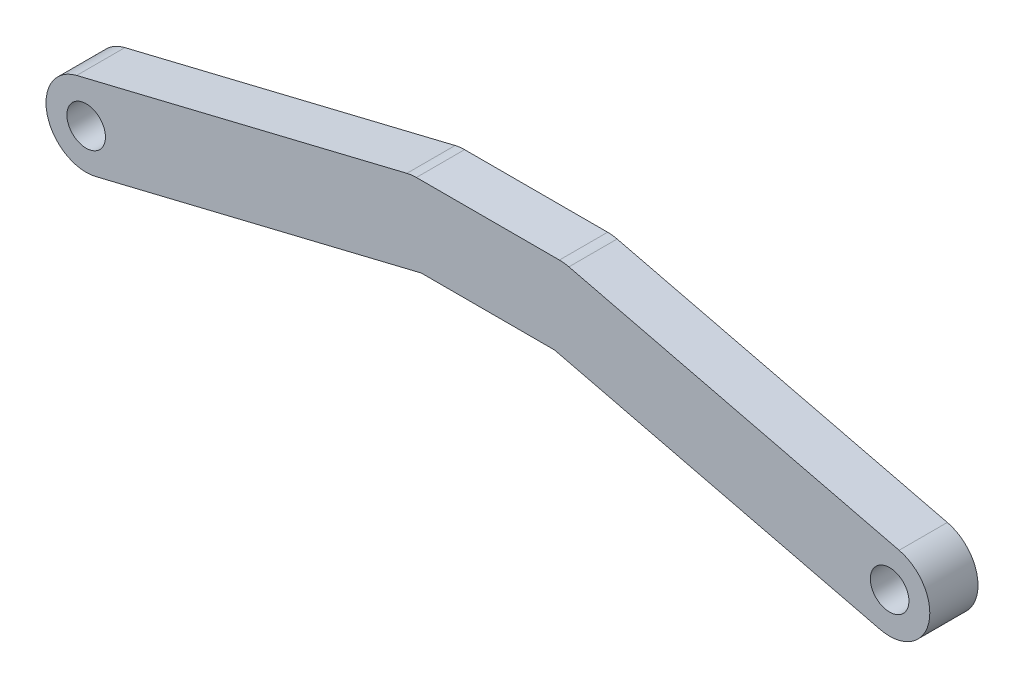
from build123d import *

# Parameters (mm, degrees)
SKETCH1_R           = 1.2
BOSS_EXTRUDE1_DEPTH = 1.5


with BuildPart() as part:
    # Sketch1 → Boss-Extrude1 (new body, symmetric)
    with BuildSketch(Plane.XY):
        with BuildLine():
            Line((-24.40896688, -2.429131501), (-4.150358361, 2.5))
            Line((-4.150358361, 2.5), (4.150358361, 2.5))
            Line((4.150358361, 2.5), (24.40896688, -2.429131501))
            ThreePointArc((24.40896688, -2.429131501), (27.429131501, -0.59103312), (25.59103312, 2.429131501))
            Line((25.59103312, 2.429131501), (5.041156826, 7.429131501))
            ThreePointArc((5.041156826, 7.429131501), (4.747757076, 7.482219647), (4.450123705, 7.5))
            Line((4.450123705, 7.5), (-4.450123705, 7.5))
            ThreePointArc((-4.450123705, 7.5), (-4.747757076, 7.482219647), (-5.041156826, 7.429131501))
            Line((-5.041156826, 7.429131501), (-25.59103312, 2.429131501))
            ThreePointArc((-25.59103312, 2.429131501), (-27.429131501, -0.59103312), (-24.40896688, -2.429131501))
        make_face()
        with Locations((-25, 0)):
            Circle(SKETCH1_R, mode=Mode.SUBTRACT)
        with Locations((25, 0)):
            Circle(SKETCH1_R, mode=Mode.SUBTRACT)
    extrude(amount=BOSS_EXTRUDE1_DEPTH, both=True)


solid = part.part
